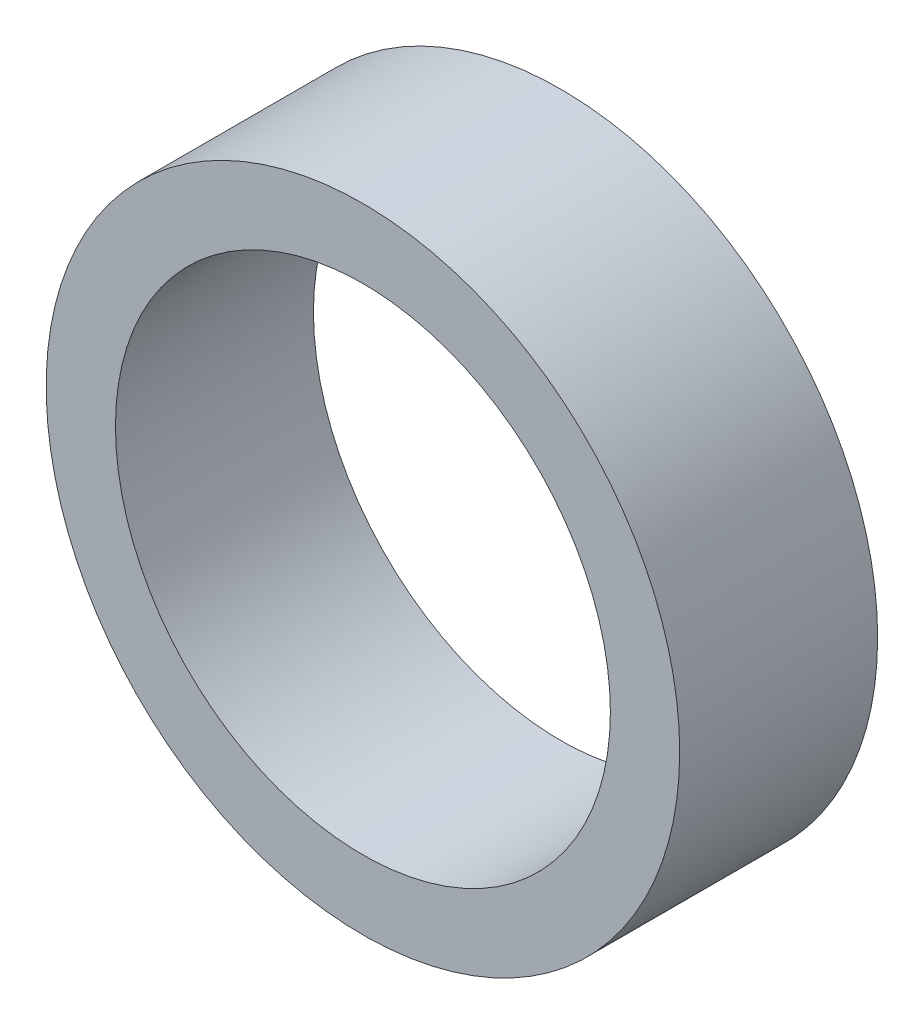
from build123d import *

# Parameters (mm, degrees)
SKETCH_1_R      = 4
SKETCH_1_R_2    = 3.125
EXTRUDE_1_DEPTH = 2.5


with BuildPart() as part:
    # 草图1 → 凸台-拉伸1 (new body)
    with BuildSketch(Plane.XY):
        Circle(SKETCH_1_R)
        Circle(SKETCH_1_R_2, mode=Mode.SUBTRACT)
    extrude(amount=EXTRUDE_1_DEPTH)


solid = part.part
